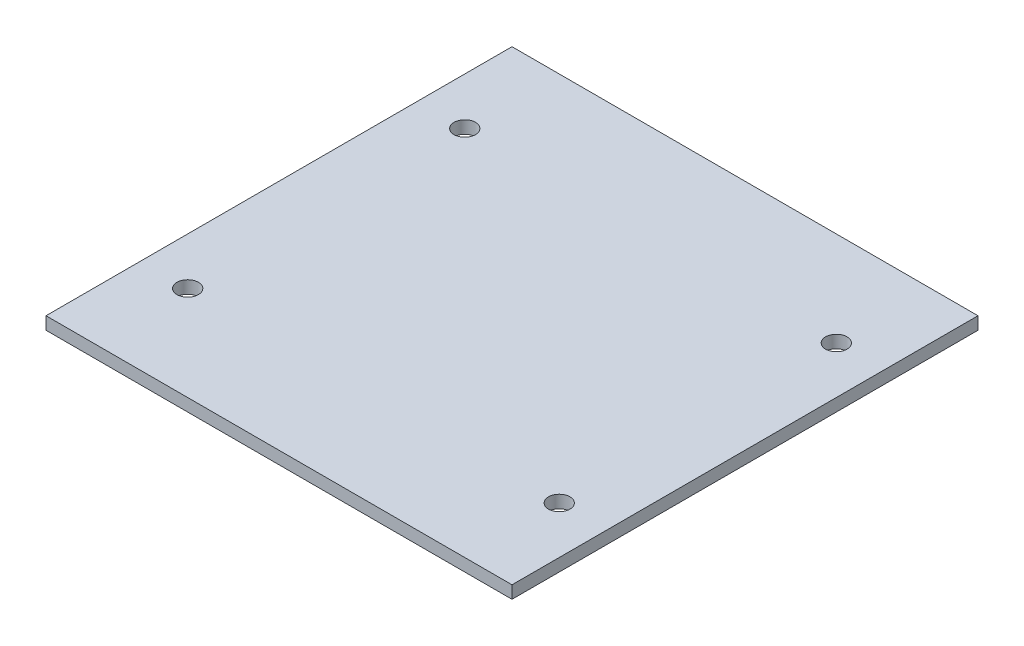
from build123d import *

# Parameters (mm, degrees)
SKETCH1_W      = 74
SKETCH1_H      = 74
EXTRUDE1_DEPTH = 2
SKETCH2_R      = 1.7
EXTRUDE2_DEPTH = 2


with BuildPart() as part:
    # Sketch1 → Extrude1 (new body)
    with BuildSketch(Plane(origin=(0, 0, 0), x_dir=(1, 0, 0), z_dir=(0, 1, 0))):
        Rectangle(SKETCH1_W, SKETCH1_H)
    extrude(amount=EXTRUDE1_DEPTH)

    # Sketch2 → Extrude2 (cut)
    with BuildSketch(Plane(origin=(0, 2, 0), x_dir=(1, 0, 0), z_dir=(0, 1, 0))):
        with Locations((29.5, 22)):
            Circle(SKETCH2_R)
        with Locations((-29.5, 22)):
            Circle(SKETCH2_R)
        with Locations((-29.5, -22)):
            Circle(SKETCH2_R)
        with Locations((29.5, -22)):
            Circle(SKETCH2_R)
    extrude(amount=-EXTRUDE2_DEPTH, mode=Mode.SUBTRACT)


solid = part.part
